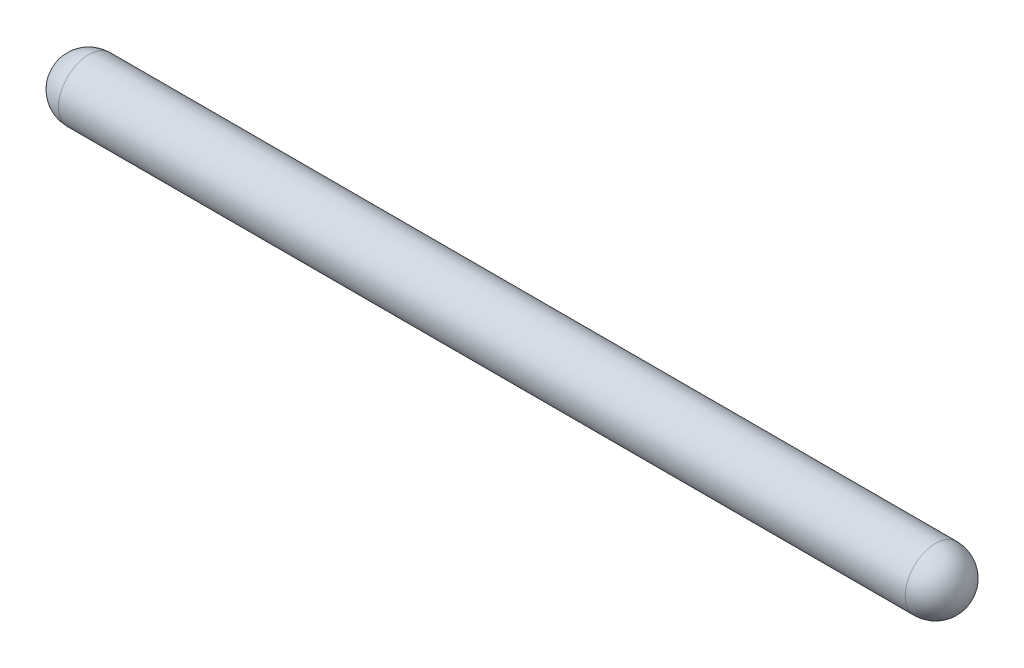
from build123d import *

# Parameters (mm, degrees)
SKETCH1_W         = 28
SKETCH1_H         = 1
DOME1_FACE_RADIUS = 1
DOME1_HEIGHT      = 1
DOME2_FACE_RADIUS = 1
DOME2_HEIGHT      = 1


with BuildPart() as part:
    # Sketch1 → Revolve1 (revolve)
    with BuildSketch(Plane.XY):
        with Locations((0, 0.5)):
            Rectangle(SKETCH1_W, SKETCH1_H)
    revolve(axis=Axis((-14, 0, 0), (1, 0, 0)))

    # Dome1: a dome of height H over a round flat face of radius A is a cap of a sphere of radius (A * A + H * H) / (2 * H)
    dome1_r = (DOME1_FACE_RADIUS * DOME1_FACE_RADIUS + DOME1_HEIGHT * DOME1_HEIGHT) / (2 * DOME1_HEIGHT)
    dome1_base = Plane((-14, 0, 0), z_dir=(-1, 0, 0))
    with Locations(dome1_base.offset(DOME1_HEIGHT - dome1_r)):
        dome1_ball = Sphere(dome1_r, mode=Mode.PRIVATE)
    add(split(dome1_ball, bisect_by=dome1_base, keep=Keep.TOP, mode=Mode.PRIVATE))

    # Dome2: a dome of height H over a round flat face of radius A is a cap of a sphere of radius (A * A + H * H) / (2 * H)
    dome2_r = (DOME2_FACE_RADIUS * DOME2_FACE_RADIUS + DOME2_HEIGHT * DOME2_HEIGHT) / (2 * DOME2_HEIGHT)
    dome2_base = Plane((14, 0, 0), z_dir=(1, 0, 0))
    with Locations(dome2_base.offset(DOME2_HEIGHT - dome2_r)):
        dome2_ball = Sphere(dome2_r, mode=Mode.PRIVATE)
    add(split(dome2_ball, bisect_by=dome2_base, keep=Keep.TOP, mode=Mode.PRIVATE))


solid = part.part
